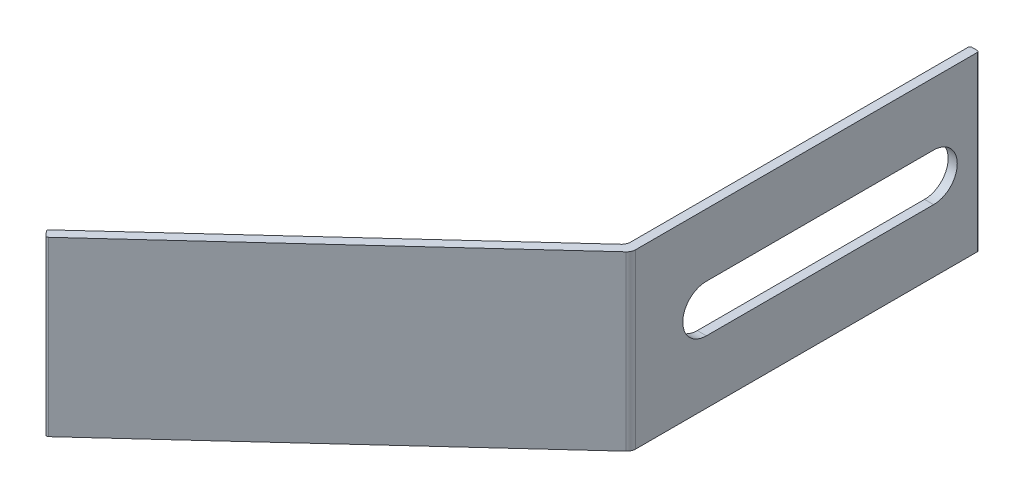
from build123d import *

# Parameters (mm, degrees)
EXTRUDE_THIN1_DEPTH = 9.5
FILLET1_R           = 1
FILLET2_R           = 0.2
CUT_EXTRUDE1_DEPTH  = 2


with BuildPart() as part:
    # Sketch1 → Extrude-Thin1 (new body, symmetric)
    with BuildSketch(Plane(origin=(0, 0, 0), x_dir=(1, 0, 0), z_dir=(0, 1, 0))):
        Polygon((-0.5, 0), (-0.5, -37.779994735), (-33.810186195, -68.303156757), (-33.134595987, -69.040434094), (0.5, -38.220005265), (0.5, 0), align=None)
    extrude(amount=EXTRUDE_THIN1_DEPTH, both=True)

    # Fillet1
    fillet1_edges = [part.edges().sort_by_distance(p)[0] for p in [
        (-0.5, 0, 37.779994735),
        (0.5, 0, 38.220005265),
    ]]
    fillet(fillet1_edges, radius=FILLET1_R)

    # Fillet2
    fillet2_edges = [part.edges().sort_by_distance(p)[0] for p in [
        (-33.810186195, 0, 68.303156757),
        (-0.5, 0, 0),
        (0.5, 0, 0),
        (-33.134595987, 0, 69.040434094),
    ]]
    fillet(fillet2_edges, radius=FILLET2_R)

    # Sketch2 → Cut-Extrude1 (cut, through all)
    with BuildSketch(Plane.ZY.offset(0.5)):
        with BuildLine():
            Line((5, 2.6), (30, 2.6))
            ThreePointArc((30, 2.6), (32.6, 0), (30, -2.6))
            Line((30, -2.6), (5, -2.6))
            ThreePointArc((5, -2.6), (2.4, 0), (5, 2.6))
        make_face()
    extrude(amount=-CUT_EXTRUDE1_DEPTH, mode=Mode.SUBTRACT)


solid = part.part
